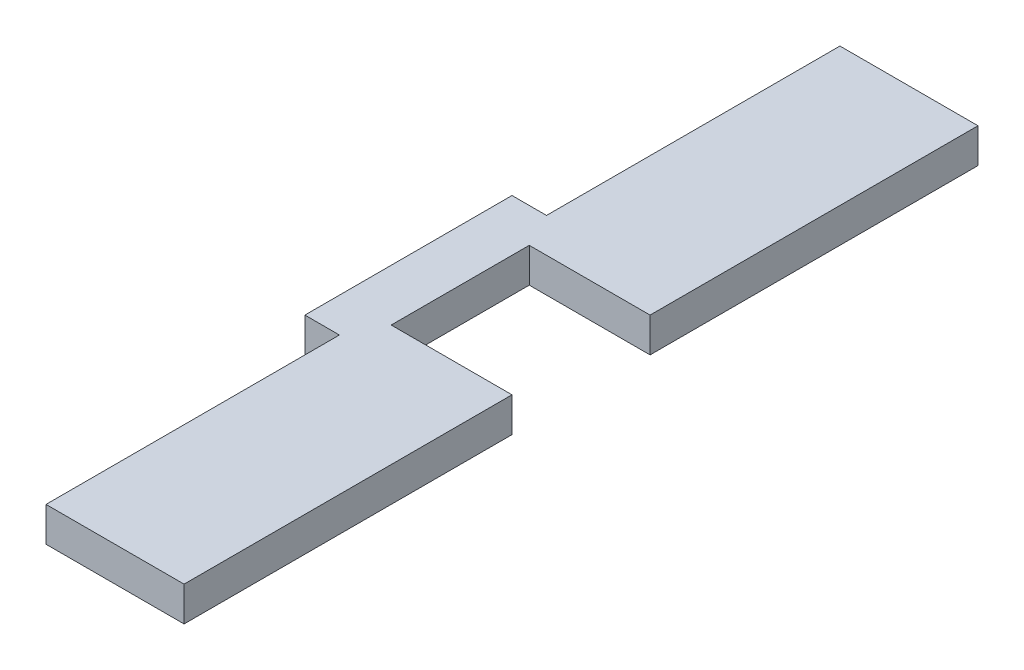
from build123d import *

# Parameters (mm, degrees)
BOSS_EXTRUDE1_DEPTH = 3.175


with BuildPart() as part:
    # Sketch1 → Boss-Extrude1 (new body)
    with BuildSketch(Plane(origin=(0, 0, 0), x_dir=(1, 0, 0), z_dir=(0, 1, 0))):
        Polygon((0, 26.9875), (0, 0), (12.7, 0), (12.7, 30.1625), (1.5875, 30.1625), (1.5875, 42.8625), (12.7, 42.8625), (12.7, 73.025), (0, 73.025), (0, 46.0375), (-3.175, 46.0375), (-3.175, 26.9875), align=None)
    extrude(amount=BOSS_EXTRUDE1_DEPTH)


solid = part.part
